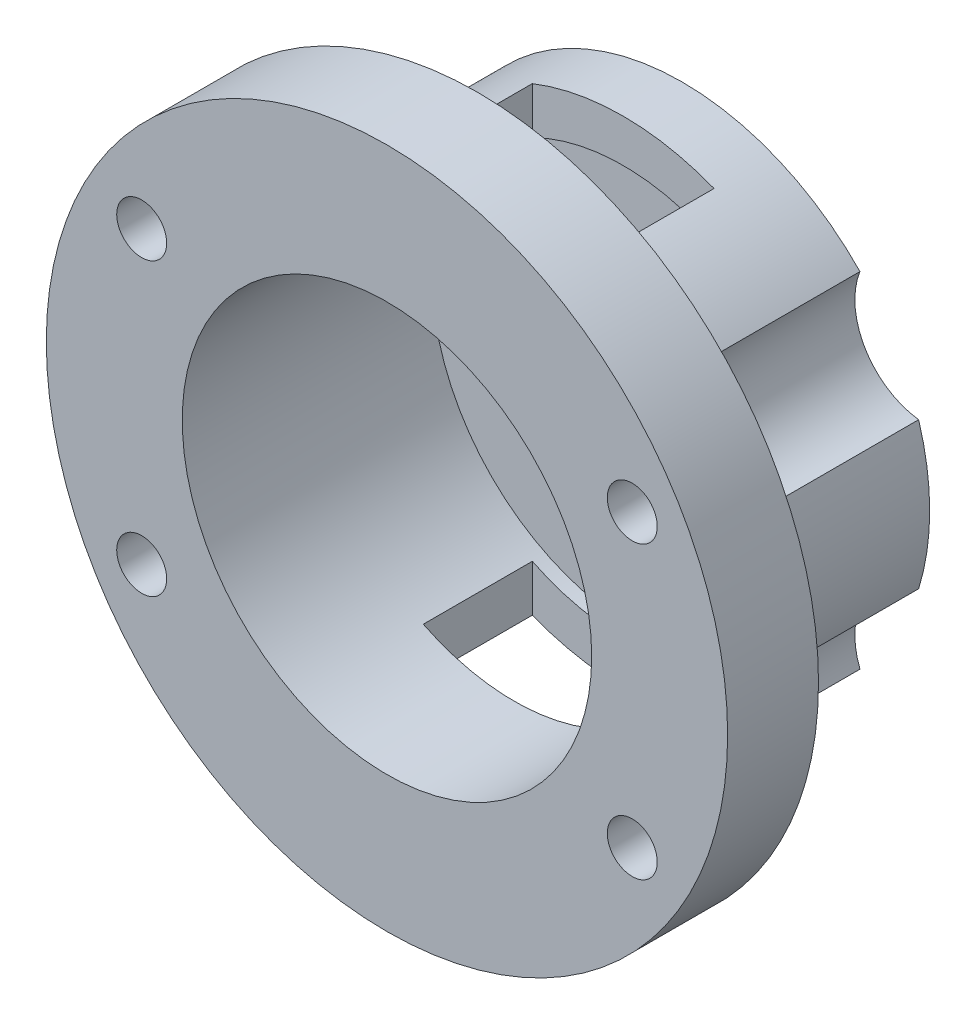
from build123d import *
from build123d.topology import SkipClean

# Parameters (mm, degrees)
SKETCH_1_R               = 37.5
SKETCH_1_R_2             = 2.75
EXTRUDE_1_DEPTH          = 20
SKETCH_2_R               = 22.536189363
CUT_EXTRUDE_1_DEPTH      = 12
SKETCH_8_R               = 37.5
SKETCH_8_R_2             = 27.240226037
CUT_EXTRUDE_4_DEPTH      = 10
SKETCH_9_R               = 8
CUT_EXTRUDE_5_DEPTH      = 10
EXTRUDE_START            = 10
EXTRUDE_2_DEPTH          = 10
SKETCH_11_R              = 45
EXTRUDE_3_DEPTH          = 5
SKETCH_13_R              = 1.5
CUT_EXTRUDE_6_DEPTH      = 10
SKETCH_14_R              = 22.536189363
CUT_EXTRUDE_7_DEPTH      = 68.668308683
CUT_EXTRUDE_8_DEPTH      = 67.708320321
CUT_EXTRUDE_8_DEPTH_BACK = 67.708320321
SKETCH_15_W              = 20
SKETCH_15_H              = 12
SKETCH_17_R              = 45
CUT_EXTRUDE_11_DEPTH     = 10
EXTRUDE_4_DEPTH          = 2.5
EXTRUDE_4_DEPTH_BACK     = 2.5
SKETCH_19_R              = 22.536189363
SKETCH_21_R              = 1.5
CUT_EXTRUDE_12_DEPTH     = 63.199276523
EXTRUDE_START_2          = 2.5
SKETCH_22_R              = 22.536189363
EXTRUDE_6_DEPTH          = 2.5


with BuildPart() as part:
    # 草图1 → 凸台-拉伸1 (new body)
    with BuildSketch(Plane.XY):
        Circle(SKETCH_1_R)
        with Locations((-27, 16)):
            Circle(SKETCH_1_R_2, mode=Mode.SUBTRACT)
        with Locations((27, 16)):
            Circle(SKETCH_1_R_2, mode=Mode.SUBTRACT)
        with Locations((-27, -16)):
            Circle(SKETCH_1_R_2, mode=Mode.SUBTRACT)
        with Locations((27, -16)):
            Circle(SKETCH_1_R_2, mode=Mode.SUBTRACT)
    extrude(amount=EXTRUDE_1_DEPTH)

    # 草图2 → 切除-拉伸1 (cut)
    with BuildSketch(Plane.XY.offset(20)):
        Circle(SKETCH_2_R)
    extrude(amount=-CUT_EXTRUDE_1_DEPTH, mode=Mode.SUBTRACT)

    # 草图8 → 切除-拉伸4 (cut)
    with BuildSketch(Plane(origin=(0, 0, 0), x_dir=(-1, 0, 0), z_dir=(0, 0, -1))):
        Circle(SKETCH_8_R)
        Circle(SKETCH_8_R_2, mode=Mode.SUBTRACT)
    extrude(amount=-CUT_EXTRUDE_4_DEPTH, mode=Mode.SUBTRACT)

    # 草图9 → 切除-拉伸5 (cut)
    with BuildSketch(Plane(origin=(0, 0, 0), x_dir=(-1, 0, 0), z_dir=(0, 0, -1))):
        with Locations((-27, 16)):
            Circle(SKETCH_9_R)
        with Locations((27, 16)):
            Circle(SKETCH_9_R)
        with Locations((-27, -16)):
            Circle(SKETCH_9_R)
        with Locations((27, -16)):
            Circle(SKETCH_9_R)
    extrude(amount=-CUT_EXTRUDE_5_DEPTH, mode=Mode.SUBTRACT)

    # 草图10 → 凸台-拉伸2 (add)
    with SkipClean():  # the faces are left unmerged after this step: merging them gives an invalid solid
        with BuildSketch(Plane(origin=(0, 0, 0), x_dir=(-1, 0, 0), z_dir=(0, 0, -1)).offset(EXTRUDE_START)):
            with BuildLine():
                ThreePointArc((-19.565154934, -18.95348588), (0, -27.240226037), (19.565154934, -18.95348588))
                ThreePointArc((19.565154934, -18.95348588), (20.117667731, -11.921580878), (26.020436633, -8.060198012))
                ThreePointArc((26.020436633, -8.060198012), (27.240226037, 0), (26.020436633, 8.060198012))
                ThreePointArc((26.020436633, 8.060198012), (20.117667731, 11.921580878), (19.565154934, 18.95348588))
                ThreePointArc((19.565154934, 18.95348588), (0, 27.240226037), (-19.565154934, 18.95348588))
                ThreePointArc((-19.565154934, 18.95348588), (-20.117667731, 11.921580878), (-26.020436633, 8.060198012))
                ThreePointArc((-26.020436633, 8.060198012), (-27.240226037, 0), (-26.020436633, -8.060198012))
                ThreePointArc((-26.020436633, -8.060198012), (-20.117667731, -11.921580878), (-19.565154934, -18.95348588))
            make_face()
        extrude(amount=-EXTRUDE_2_DEPTH)

    # 草图11 → 凸台-拉伸3 (add)
    with SkipClean():  # the faces are left unmerged after this step: merging them gives an invalid solid
        with BuildSketch(Plane(origin=(0, 0, -10), x_dir=(-1, 0, 0), z_dir=(0, 0, -1))):
            Circle(SKETCH_11_R)
        extrude(amount=EXTRUDE_3_DEPTH)

    # 草图13 → 切除-拉伸6 (cut)
    with SkipClean():  # the faces are left unmerged after this step: merging them gives an invalid solid
        with BuildSketch(Plane(origin=(0, 0, -15), x_dir=(-1, 0, 0), z_dir=(0, 0, -1))):
            with Locations((0, 36.415999231)):
                Circle(SKETCH_13_R)
            with Locations((-36.415999231, 0)):
                Circle(SKETCH_13_R)
            with Locations((0, -36.415999231)):
                Circle(SKETCH_13_R)
            with Locations((36.415999231, 0)):
                Circle(SKETCH_13_R)
        extrude(amount=-CUT_EXTRUDE_6_DEPTH, mode=Mode.SUBTRACT)

    # 草图14 → 切除-拉伸7 (cut, through all)
    with SkipClean():  # the faces are left unmerged after this step: merging them gives an invalid solid
        with BuildSketch(Plane.XY.offset(8)):
            Circle(SKETCH_14_R)
        extrude(amount=-CUT_EXTRUDE_7_DEPTH, mode=Mode.SUBTRACT)

    # 草图15 → 切除-拉伸8 (cut, two sides: drawn at the far end of the back side and taken through both)
    with SkipClean():  # the faces are left unmerged after this step: merging them gives an invalid solid
        with BuildSketch(Plane(origin=(0, 0, 0), x_dir=(1, 0, 0), z_dir=(0, 1, 0)).offset(-CUT_EXTRUDE_8_DEPTH_BACK)):
            Rectangle(SKETCH_15_W, SKETCH_15_H)
        extrude(amount=CUT_EXTRUDE_8_DEPTH + CUT_EXTRUDE_8_DEPTH_BACK, mode=Mode.SUBTRACT)

    # 草图17 → 切除-拉伸11 (cut)
    with SkipClean():  # the faces are left unmerged after this step: merging them gives an invalid solid
        with BuildSketch(Plane.XY.offset(-10)):
            Circle(SKETCH_17_R)
        extrude(amount=-CUT_EXTRUDE_11_DEPTH, mode=Mode.SUBTRACT)

    # 草图19 → 凸台-拉伸4 (add, two sides: drawn at the far end of the back side and taken through both)
    with SkipClean():  # the faces are left unmerged after this step: merging them gives an invalid solid
        with BuildSketch(Plane(origin=(0, 0, -10), x_dir=(-1, 0, 0), z_dir=(0, 0, -1)).offset(-EXTRUDE_4_DEPTH_BACK)):
            Circle(SKETCH_19_R)
        extrude(amount=EXTRUDE_4_DEPTH + EXTRUDE_4_DEPTH_BACK)

    # 草图21 → 切除-拉伸12 (cut, through all)
    with SkipClean():  # the faces are left unmerged after this step: merging them gives an invalid solid
        with BuildSketch(Plane(origin=(0, 0, -12.5), x_dir=(-1, 0, 0), z_dir=(0, 0, -1))):
            with Locations((0, 7)):
                Circle(SKETCH_21_R)
            with Locations((-7, 0)):
                Circle(SKETCH_21_R)
            with Locations((7, 0)):
                Circle(SKETCH_21_R)
            with Locations((0, -7)):
                Circle(SKETCH_21_R)
        extrude(amount=-CUT_EXTRUDE_12_DEPTH, mode=Mode.SUBTRACT)

    # 草图22 → 凸台-拉伸6 (add)
    with SkipClean():  # the faces are left unmerged after this step: merging them gives an invalid solid
        with BuildSketch(Plane(origin=(0, 0, -10), x_dir=(-1, 0, 0), z_dir=(0, 0, -1)).offset(EXTRUDE_START_2)):
            with BuildLine():
                ThreePointArc((-26.020436633, 8.060198012), (-27.240226037, 0), (-26.020436633, -8.060198012))
                ThreePointArc((-26.020436633, -8.060198012), (-20.117667731, -11.921580878), (-19.565154934, -18.95348588))
                ThreePointArc((-19.565154934, -18.95348588), (0, -27.240226037), (19.565154934, -18.95348588))
                ThreePointArc((19.565154934, -18.95348588), (20.117667731, -11.921580878), (26.020436633, -8.060198012))
                ThreePointArc((26.020436633, -8.060198012), (27.240226037, 0), (26.020436633, 8.060198012))
                ThreePointArc((26.020436633, 8.060198012), (20.117667731, 11.921580878), (19.565154934, 18.95348588))
                ThreePointArc((19.565154934, 18.95348588), (0, 27.240226037), (-19.565154934, 18.95348588))
                ThreePointArc((-19.565154934, 18.95348588), (-20.117667731, 11.921580878), (-26.020436633, 8.060198012))
            make_face()
            Circle(SKETCH_22_R, mode=Mode.SUBTRACT)
        extrude(amount=-EXTRUDE_6_DEPTH)


solid = part.part
